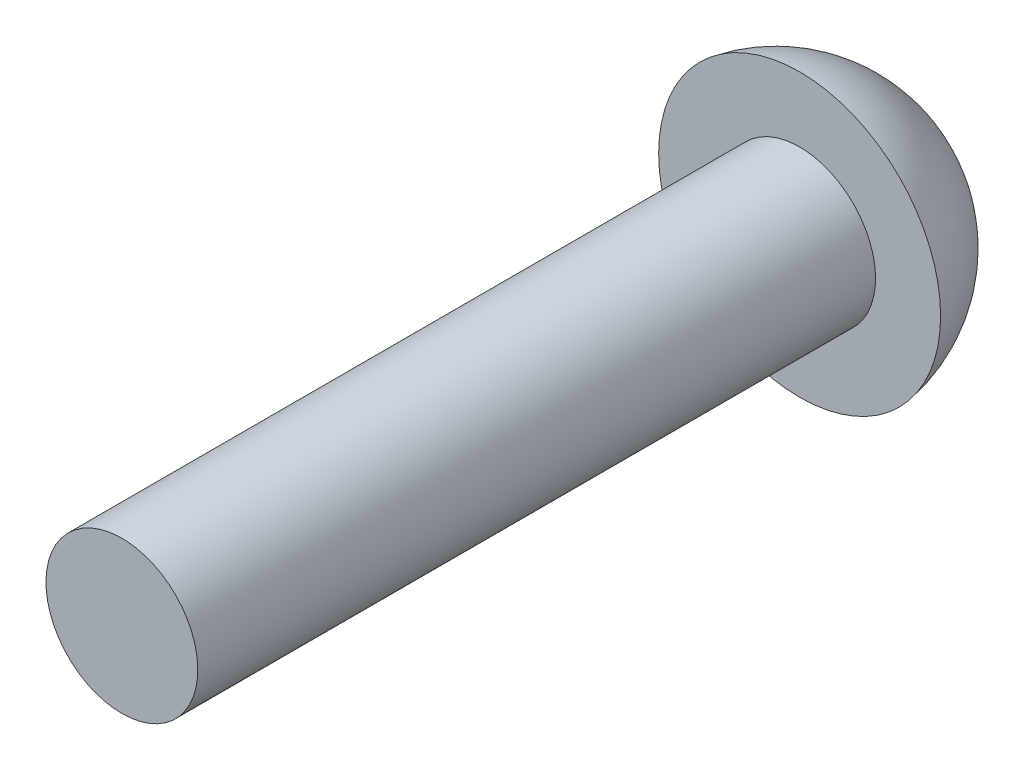
from build123d import *


with BuildPart() as part:
    # Sketch2 → Revolve1 (revolve)
    with BuildSketch(Plane(origin=(0, 0, 0), x_dir=(0, 0, -1), z_dir=(1, 0, 0))):
        with BuildLine():
            Line((0, 0), (0, 1.4224))
            Line((0, 1.4224), (12.7, 1.4224))
            Line((12.7, 1.4224), (12.7, 2.6416))
            ThreePointArc((12.7, 2.6416), (14.30141941, 1.730185655), (14.9352, 0))
            Line((14.9352, 0), (0, 0))
        make_face()
    revolve(axis=Axis((0, 0, 0), (0, 0, -1)))


solid = part.part
